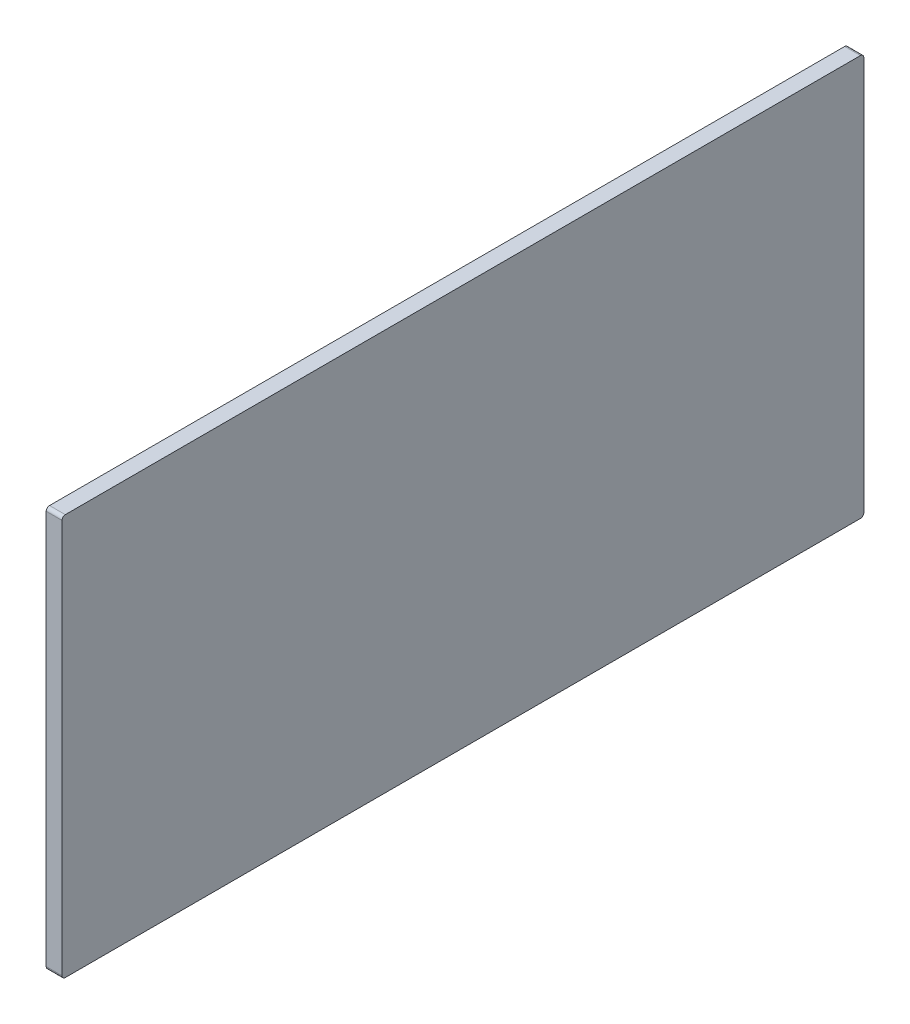
from build123d import *

# Parameters (mm, degrees)
SKETCH1_W           = 609.6
SKETCH1_H           = 304.8
BOSS_EXTRUDE1_DEPTH = 11.9888
FILLET1_R           = 2.54


with BuildPart() as part:
    # Sketch1 → Boss-Extrude1 (new body)
    with BuildSketch(Plane.ZY.offset(311.15)):
        with Locations((0, 330.2)):
            Rectangle(SKETCH1_W, SKETCH1_H)
    extrude(amount=BOSS_EXTRUDE1_DEPTH)

    # Fillet1
    fillet1_edges = [part.edges().sort_by_distance(p)[0] for p in [
        (-317.1444, 482.6, -304.8),
        (-317.1444, 482.6, 304.8),
        (-317.1444, 177.8, 304.8),
        (-317.1444, 177.8, -304.8),
    ]]
    fillet(fillet1_edges, radius=FILLET1_R)


solid = part.part
